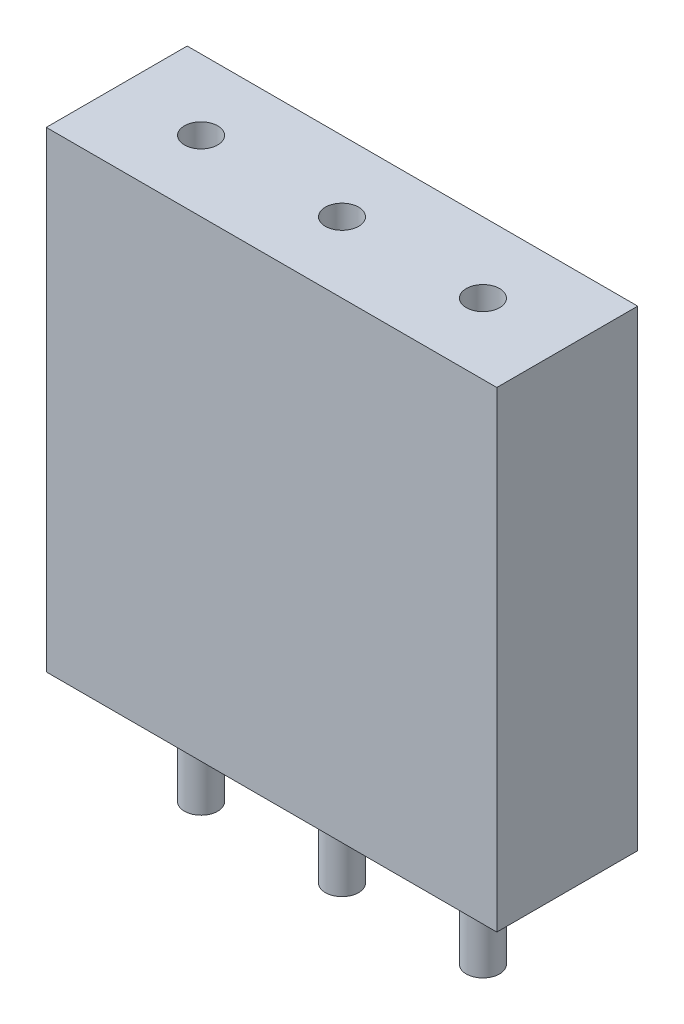
from build123d import *

# Parameters (mm, degrees)
SKETCH_1_W          = 8.12
SKETCH_1_H          = 2.54
EXTRUDE_1_DEPTH     = 8.5
SKETCH_2_R          = 0.3
CUT_EXTRUDE_1_DEPTH = 8.5
SKETCH_3_R          = 0.3
EXTRUDE_2_DEPTH     = 1.9
EXTRUDE_2_2_DEPTH   = 1.9
EXTRUDE_2_3_DEPTH   = 1.9


with BuildPart() as part:
    # Эскиз1 → Бобышка-Вытянуть1 (new body)
    with BuildSketch(Plane(origin=(0, 0, 0), x_dir=(1, 0, 0), z_dir=(0, 1, 0))):
        Rectangle(SKETCH_1_W, SKETCH_1_H)
    extrude(amount=EXTRUDE_1_DEPTH)

    # Эскиз2 → Вырез-Вытянуть1 (cut)
    with BuildSketch(Plane(origin=(0, 8.5, 0), x_dir=(1, 0, 0), z_dir=(0, 1, 0))):
        with Locations((-2.54, 0)):
            Circle(SKETCH_2_R)
        Circle(SKETCH_2_R)
        with Locations((2.54, 0)):
            Circle(SKETCH_2_R)
    extrude(amount=-CUT_EXTRUDE_1_DEPTH, mode=Mode.SUBTRACT)


with BuildPart() as body_2:
    # Эскиз3 → Бобышка-Вытянуть2 (new body)
    with BuildSketch(Plane.XZ):
        with Locations((-2.54, 0)):
            Circle(SKETCH_3_R)
    extrude(amount=EXTRUDE_2_DEPTH)


with BuildPart() as body_3:
    # Эскиз3 → Extrude 2 2 (new body)
    with BuildSketch(Plane.XZ):
        Circle(SKETCH_3_R)
    extrude(amount=EXTRUDE_2_2_DEPTH)


with BuildPart() as body_4:
    # Эскиз3 → Extrude 2 3 (new body)
    with BuildSketch(Plane.XZ):
        with Locations((2.54, 0)):
            Circle(SKETCH_3_R)
    extrude(amount=EXTRUDE_2_3_DEPTH)


solid = Compound([part.part, body_2.part, body_3.part, body_4.part])
